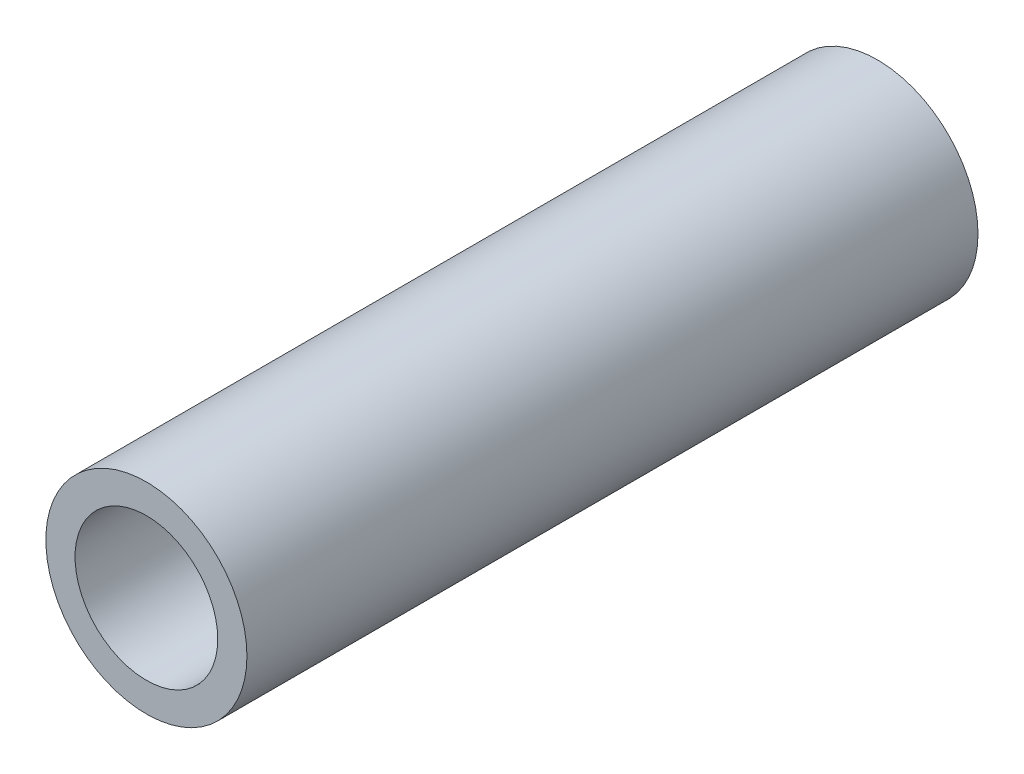
from build123d import *

# Parameters (mm, degrees)
SKETCH1_R           = 3.937
SKETCH1_R_2         = 2.794
BOSS_EXTRUDE1_DEPTH = 28.6258


with BuildPart() as part:
    # Sketch1 → Boss-Extrude1 (new body)
    with BuildSketch(Plane.XY):
        Circle(SKETCH1_R)
        Circle(SKETCH1_R_2, mode=Mode.SUBTRACT)
    extrude(amount=BOSS_EXTRUDE1_DEPTH)


solid = part.part
